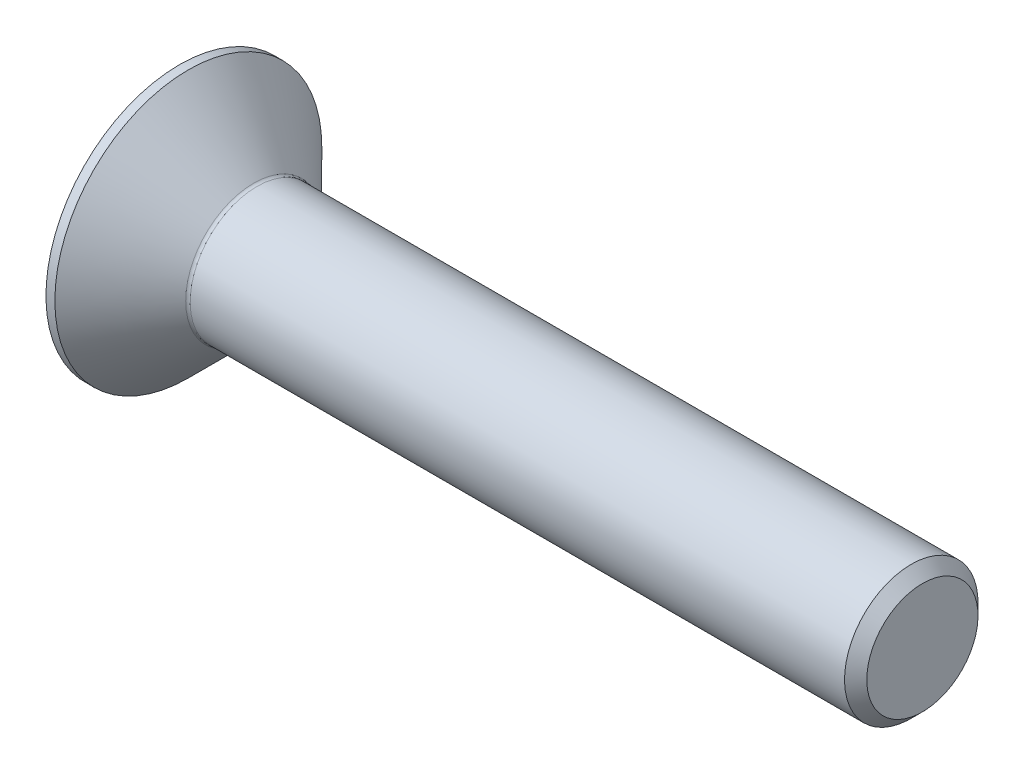
from build123d import *

# Parameters (mm, degrees)
CUT_EXTRUDE_1_DEPTH = 1.2
CHAMFER_1_SIZE      = 0.25
FILLET_1_R          = 0.1


with BuildPart() as part:
    # 草圖1 → 旋轉1 (revolve)
    with BuildSketch(Plane.XY):
        Polygon((0, 3), (0, 0), (16.7, 0), (16.7, 1.5), (1.7, 1.5), (0.2, 3), align=None)
    revolve(axis=Axis((0, 0, 0), (1, 0, 0)))

    # 草圖2 → 除料-伸長1 (cut)
    with BuildSketch(Plane.ZY):
        Polygon((-1, -0.577350269), (0, -1.154700538), (1, -0.577350269), (1, 0.577350269), (0, 1.154700538), (-1, 0.577350269), align=None)
    extrude(amount=-CUT_EXTRUDE_1_DEPTH, mode=Mode.SUBTRACT)

    # 導角1
    chamfer_1_edges = [part.edges().sort_by_distance(p)[0] for p in [
        (16.7, -1.5, 0),
    ]]
    chamfer(chamfer_1_edges, length=CHAMFER_1_SIZE)

    # 圓角1
    fillet_1_edges = [part.edges().sort_by_distance(p)[0] for p in [
        (1.7, -1.5, 0),
    ]]
    fillet(fillet_1_edges, radius=FILLET_1_R)


solid = part.part
